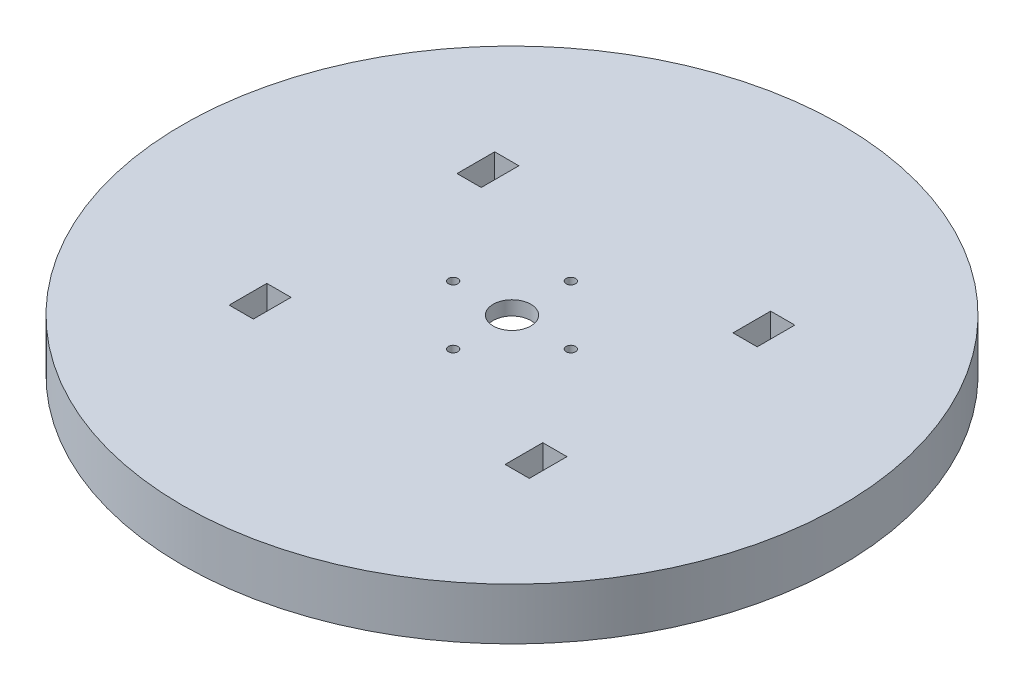
from build123d import *

# Parameters (mm, degrees)
SKETCH1_R            = 22.5
SKETCH1_R_2          = 1
SKETCH1_R_3          = 4
BOSS_EXTRUDE7_DEPTH  = 3
SKETCH1_15_R         = 67.5
SKETCH1_15_W         = 5.138307475
SKETCH1_15_H         = 8
SKETCH1_15_R_2       = 22.5
BOSS_EXTRUDE8_DEPTH  = 8
SKETCH1_20_R         = 70
SKETCH1_20_R_2       = 67.5
BOSS_EXTRUDE10_DEPTH = 11


with BuildPart() as part:
    # Sketch1 → Boss-Extrude7 (new body)
    with BuildSketch(Plane(origin=(0, 0, 0), x_dir=(1, 0, 0), z_dir=(0, 1, 0))):
        Circle(SKETCH1_R)
        with Locations((0, -12.5)):
            Circle(SKETCH1_R_2, mode=Mode.SUBTRACT)
        with Locations((-12.5, 0)):
            Circle(SKETCH1_R_2, mode=Mode.SUBTRACT)
        Circle(SKETCH1_R_3, mode=Mode.SUBTRACT)
        with Locations((12.5, 0)):
            Circle(SKETCH1_R_2, mode=Mode.SUBTRACT)
        with Locations((0, 12.5)):
            Circle(SKETCH1_R_2, mode=Mode.SUBTRACT)
    extrude(amount=-BOSS_EXTRUDE7_DEPTH)

    # Sketch1_15 → Boss-Extrude8 (add)
    with BuildSketch(Plane(origin=(0, 0, 0), x_dir=(1, 0, 0), z_dir=(0, 1, 0))):
        Circle(SKETCH1_15_R)
        with Locations((-29.307217935, -24.2)):
            Rectangle(SKETCH1_15_W, SKETCH1_15_H, mode=Mode.SUBTRACT)
        with Locations((29.307217935, -24.2)):
            Rectangle(SKETCH1_15_W, SKETCH1_15_H, mode=Mode.SUBTRACT)
        with Locations((-29.307217935, 24.2)):
            Rectangle(SKETCH1_15_W, SKETCH1_15_H, mode=Mode.SUBTRACT)
        Circle(SKETCH1_15_R_2, mode=Mode.SUBTRACT)
        with Locations((29.307217935, 24.2)):
            Rectangle(SKETCH1_15_W, SKETCH1_15_H, mode=Mode.SUBTRACT)
    extrude(amount=-BOSS_EXTRUDE8_DEPTH)

    # Sketch1_20 → Boss-Extrude10 (add)
    with BuildSketch(Plane(origin=(0, 0, 0), x_dir=(1, 0, 0), z_dir=(0, 1, 0))):
        Circle(SKETCH1_20_R)
        Circle(SKETCH1_20_R_2, mode=Mode.SUBTRACT)
    extrude(amount=-BOSS_EXTRUDE10_DEPTH)


solid = part.part
